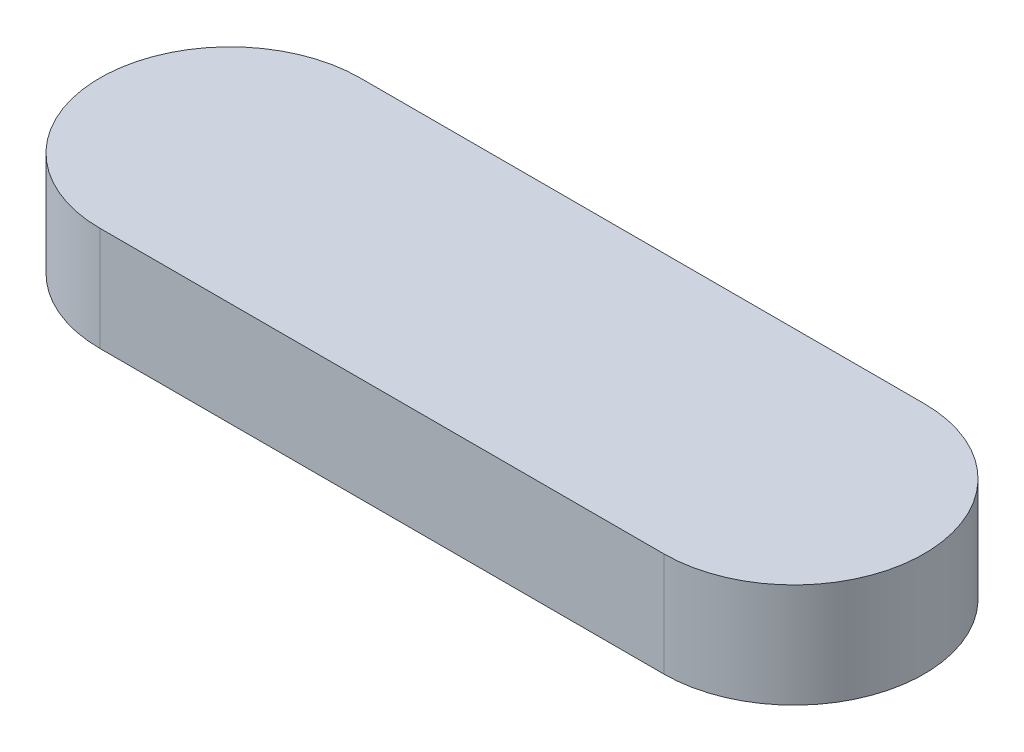
from build123d import *

# Parameters (mm, degrees)
BOSS_EXTRUDE1_DEPTH = 12


with BuildPart() as part:
    # Sketch1 → Boss-Extrude1 (new body)
    with BuildSketch(Plane(origin=(0, 0, 0), x_dir=(1, 0, 0), z_dir=(0, 1, 0))):
        with BuildLine():
            Line((-32.5, 15), (32.5, 15))
            ThreePointArc((32.5, 15), (47.5, 0), (32.5, -15))
            Line((32.5, -15), (-32.5, -15))
            ThreePointArc((-32.5, -15), (-47.5, 0), (-32.5, 15))
        make_face()
    extrude(amount=BOSS_EXTRUDE1_DEPTH)


solid = part.part
